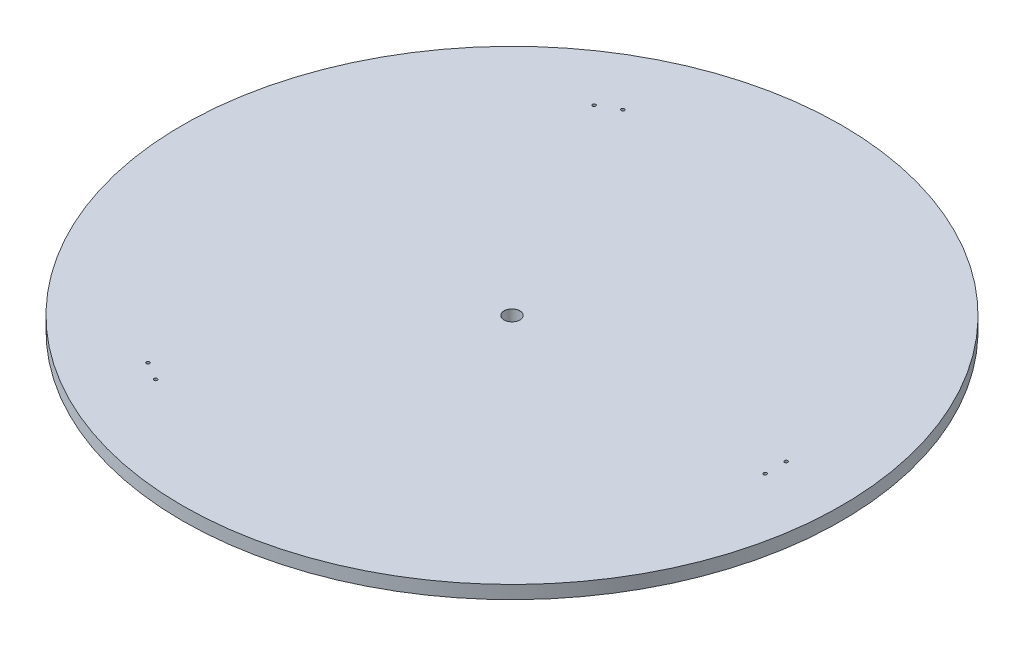
from build123d import *

# Parameters (mm, degrees)
ESQUISSE1_R                  = 250
BOSS_EXTRU_1_DEPTH           = 5
D_GAGEMENT_M101_D            = 12
D_GAGEMENT_M101_CSINK_D      = 12.05
D_GAGEMENT_M101_CSINK_ANGLE  = 90
ESQUISSE6_R                  = 1.25
ENL_V_MAT_EXTRU_1_DEPTH      = 11
R_P_TITION_CIRCULAIRE1_COUNT = 3


with BuildPart() as part:
    # Esquisse1 → Boss.-Extru.1 (new body, symmetric)
    with BuildSketch(Plane(origin=(0, 0, 0), x_dir=(1, 0, 0), z_dir=(0, 1, 0))):
        Circle(ESQUISSE1_R)
    extrude(amount=BOSS_EXTRU_1_DEPTH, both=True)

    # Dégagement M101 (through all)
    with Locations(Plane(origin=(0, 5, 0), x_dir=(1, 0, 0), z_dir=(0, 1, 0))):
        with Locations((0, 0)):
            CounterSinkHole(D_GAGEMENT_M101_D / 2, D_GAGEMENT_M101_CSINK_D / 2, counter_sink_angle=D_GAGEMENT_M101_CSINK_ANGLE)

    # Esquisse6 → Enlèv. mat.-Extru.1 (cut, through all)
    with BuildSketch(Plane(origin=(0, 5, 0), x_dir=(1, 0, 0), z_dir=(0, 1, 0))):
        with Locations((200, 8)):
            Circle(ESQUISSE6_R)
        with Locations((200, -8)):
            Circle(ESQUISSE6_R)
    enl_v_mat_extru_1 = extrude(amount=-ENL_V_MAT_EXTRU_1_DEPTH, mode=Mode.SUBTRACT)

    # Répétition circulaire1: Enlèv. mat.-Extru.1 ×3 about axis
    r_p_tition_circulaire1_axis = Axis((0, 0, 0), (0, 1, 0))
    for i in range(1, R_P_TITION_CIRCULAIRE1_COUNT):
        add(enl_v_mat_extru_1.rotate(r_p_tition_circulaire1_axis, i * 360 / R_P_TITION_CIRCULAIRE1_COUNT), mode=Mode.SUBTRACT)


solid = part.part
